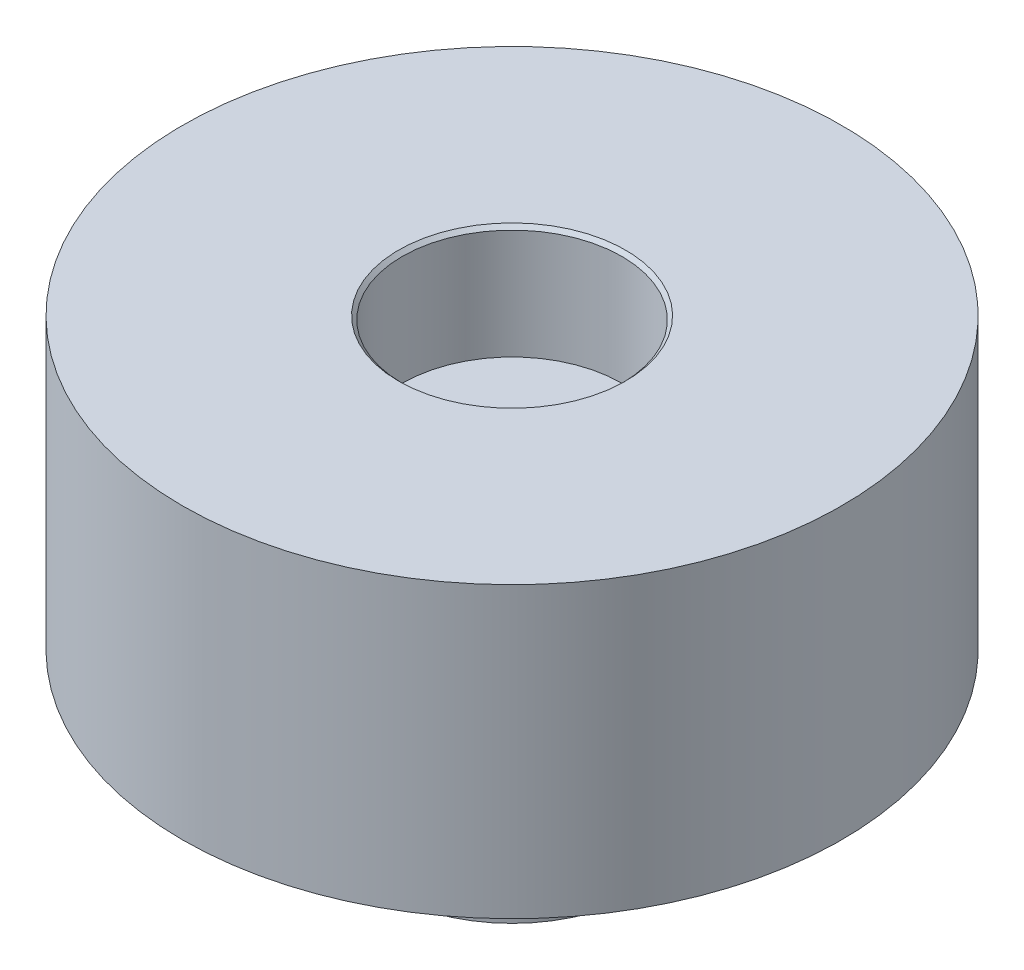
from build123d import *

# Parameters (mm, degrees)
SKETCH1_R                                       = 9
BOSS_EXTRUDE1_DEPTH                             = 7.9
SKETCH2_R                                       = 3
CUT_EXTRUDE1_DEPTH                              = 3.1
SKETCH3_R                                       = 3.5
BOSS_EXTRUDE2_DEPTH                             = 4
TAPPED_HOLE_FOR_M2_5X0_45_HELICOIL1_D           = 2.55
TAPPED_HOLE_FOR_M2_5X0_45_HELICOIL1_DEPTH       = 6.85
TAPPED_HOLE_FOR_M2_5X0_45_HELICOIL1_CSINK_D     = 3.195
TAPPED_HOLE_FOR_M2_5X0_45_HELICOIL1_CSINK_ANGLE = 90
TAPPED_HOLE_FOR_M2_5X0_45_HELICOIL1_TIP         = 0.766097289
CHAMFER1_SIZE                                   = 0.1


with BuildPart() as part:
    # Sketch1 → Boss-Extrude1 (new body)
    with BuildSketch(Plane(origin=(0, 0, 0), x_dir=(1, 0, 0), z_dir=(0, 1, 0))):
        Circle(SKETCH1_R)
    extrude(amount=BOSS_EXTRUDE1_DEPTH)

    # Sketch2 → Cut-Extrude1 (cut)
    with BuildSketch(Plane(origin=(0, 7.9, 0), x_dir=(1, 0, 0), z_dir=(0, 1, 0))):
        Circle(SKETCH2_R)
    extrude(amount=-CUT_EXTRUDE1_DEPTH, mode=Mode.SUBTRACT)

    # Sketch3 → Boss-Extrude2 (add)
    with BuildSketch(Plane.XZ):
        Circle(SKETCH3_R)
    extrude(amount=BOSS_EXTRUDE2_DEPTH)

    # Tapped Hole for M2.5x0.45 Helicoil1
    with Locations(Plane(origin=(0, -4, 0), x_dir=(-1, 0, 0), z_dir=(0, -1, 0))):
        with Locations((0, 0)):
            CounterSinkHole(TAPPED_HOLE_FOR_M2_5X0_45_HELICOIL1_D / 2, TAPPED_HOLE_FOR_M2_5X0_45_HELICOIL1_CSINK_D / 2, depth=TAPPED_HOLE_FOR_M2_5X0_45_HELICOIL1_DEPTH, counter_sink_angle=TAPPED_HOLE_FOR_M2_5X0_45_HELICOIL1_CSINK_ANGLE)
            with Locations((0, 0, -(TAPPED_HOLE_FOR_M2_5X0_45_HELICOIL1_DEPTH + TAPPED_HOLE_FOR_M2_5X0_45_HELICOIL1_TIP / 2))):  # 118° drill point
                Cone(0, TAPPED_HOLE_FOR_M2_5X0_45_HELICOIL1_D / 2, TAPPED_HOLE_FOR_M2_5X0_45_HELICOIL1_TIP, mode=Mode.SUBTRACT)

    # Chamfer1
    chamfer1_edges = [part.edges().sort_by_distance(p)[0] for p in [
        (-3, 7.9, 0),
    ]]
    chamfer(chamfer1_edges, length=CHAMFER1_SIZE)


solid = part.part
